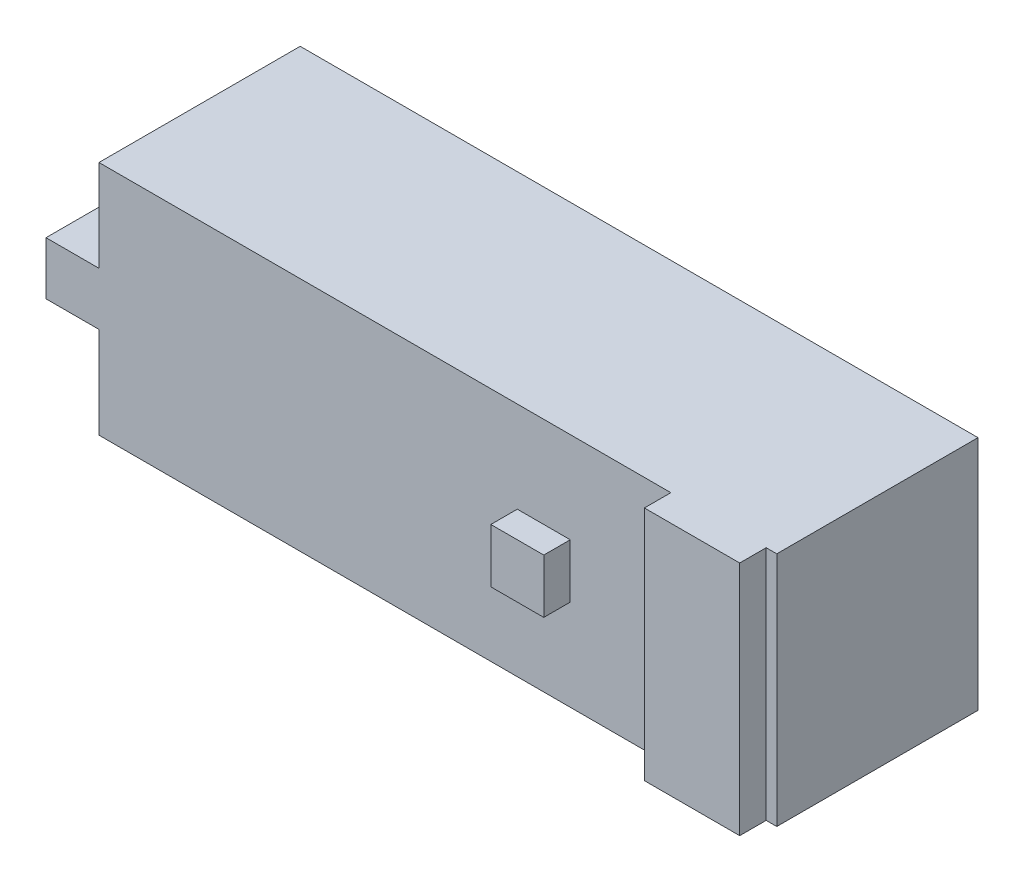
from build123d import *

# Parameters (mm, degrees)
SKETCH2_W           = 64
SKETCH2_H           = 22.3
SKETCH2_W_2         = 5
SKETCH2_H_2         = 5
BOSS_EXTRUDE1_DEPTH = 19
BOSS_EXTRUDE2_DEPTH = 8
SKETCH4_R           = 2.1
SKETCH4_W           = 5
SKETCH4_H           = 5.1
BOSS_EXTRUDE3_DEPTH = 2
SKETCH5_W           = 5
SKETCH5_H           = 5.1
SKETCH5_W_2         = 9
SKETCH5_H_2         = 22.3
BOSS_EXTRUDE4_DEPTH = 2.5


with BuildPart() as part:
    # Sketch2 → Boss-Extrude1 (new body)
    with BuildSketch(Plane.XY):
        Rectangle(SKETCH2_W, SKETCH2_H)
        with Locations((-34.5, 0)):
            Rectangle(SKETCH2_W_2, SKETCH2_H_2)
    extrude(amount=BOSS_EXTRUDE1_DEPTH)

    # Sketch3 → Boss-Extrude2 (add)
    with BuildSketch(Plane.XY):
        with BuildLine():
            ThreePointArc((-23, 1.825), (-23.707512696, 0), (-23, -1.825))
            Line((-23, -1.825), (-19, -1.825))
            ThreePointArc((-19, -1.825), (-18.475554477, -0.97867247), (-18.292487304, 0))
            ThreePointArc((-18.292487304, 0), (-18.475554477, 0.97867247), (-19, 1.825))
            Line((-19, 1.825), (-23, 1.825))
        make_face()
    extrude(amount=-BOSS_EXTRUDE2_DEPTH)

    # Sketch4 → Boss-Extrude3 (add)
    with BuildSketch(Plane(origin=(0, 0, 0), x_dir=(-1, 0, 0), z_dir=(0, 0, -1))):
        with Locations((10, 0)):
            Circle(SKETCH4_R)
        with Locations((-10, 0)):
            Rectangle(SKETCH4_W, SKETCH4_H)
    extrude(amount=BOSS_EXTRUDE3_DEPTH)

    # Sketch5 → Boss-Extrude4 (add)
    with BuildSketch(Plane.XY.offset(19)):
        with Locations((10, 0)):
            Rectangle(SKETCH5_W, SKETCH5_H)
        with Locations((26.5, 0)):
            Rectangle(SKETCH5_W_2, SKETCH5_H_2)
    extrude(amount=BOSS_EXTRUDE4_DEPTH)


solid = part.part
